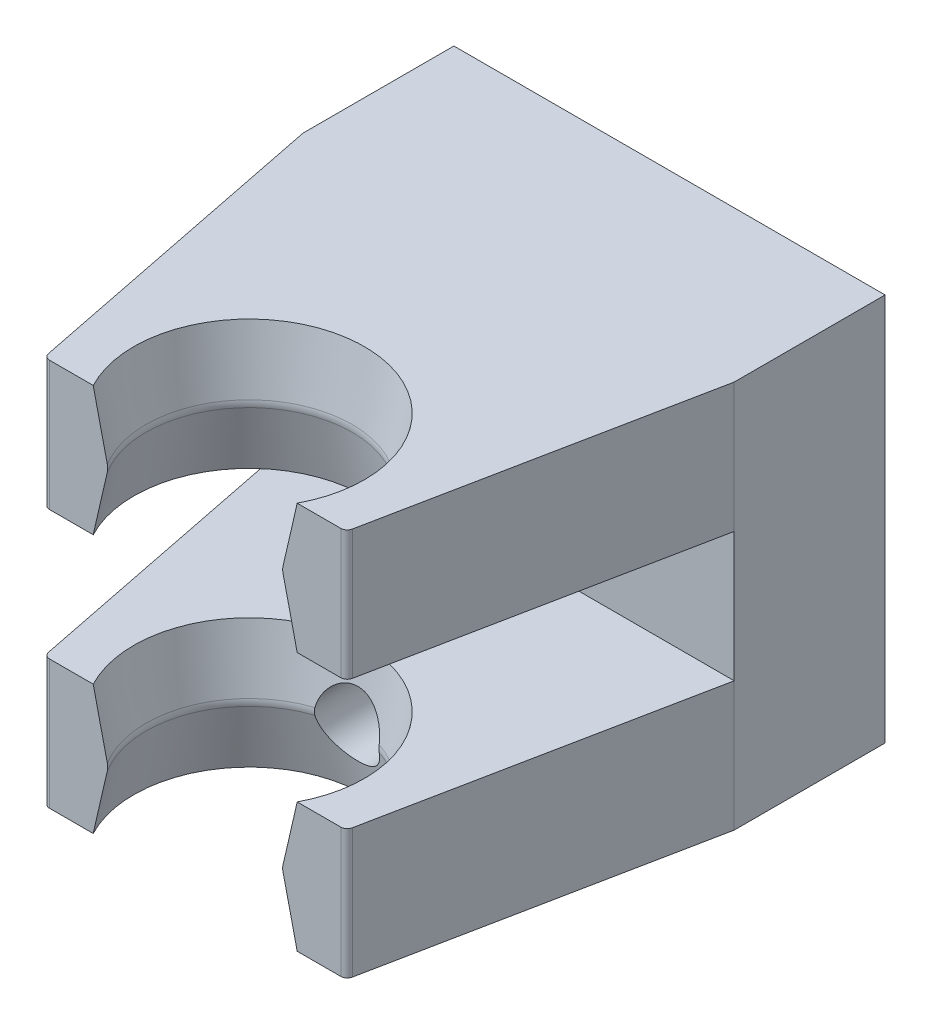
from build123d import *

# Parameters (mm, degrees)
SKETCH1_W               = 20
SKETCH1_H               = 18
BOSS_EXTRUDE1_DEPTH     = 7
SKETCH2_W               = 20
SKETCH2_H               = 6
BOSS_EXTRUDE2_DEPTH     = 15
SKETCH3_R               = 5.35
CUT_EXTRUDE1_DEPTH      = 18
SKETCH5_W               = 14
SKETCH5_H               = 6
CUT_EXTRUDE2_DEPTH      = 3.85
FILLET1_R               = 0.3
SKETCH6_W               = 20
SKETCH6_H               = 9
CUT_EXTRUDE3_DEPTH      = 16.0000001
CUT_EXTRUDE3_DEPTH_BACK = 8
SKETCH7_R               = 1.5
CUT_EXTRUDE4_DEPTH      = 1
CUT_EXTRUDE4_DEPTH_BACK = 23.0000001


with BuildPart() as part:
    # Sketch1 → Boss-Extrude1 (new body)
    with BuildSketch(Plane.XY):
        Rectangle(SKETCH1_W, SKETCH1_H)
    extrude(amount=BOSS_EXTRUDE1_DEPTH)

    # Sketch2 → Boss-Extrude2 (add)
    with BuildSketch(Plane.XY.offset(7)):
        with Locations((0, -6)):
            Rectangle(SKETCH2_W, SKETCH2_H)
        with Locations((0, 6)):
            Rectangle(SKETCH2_W, SKETCH2_H)
    extrude(amount=BOSS_EXTRUDE2_DEPTH)

    # Sketch3 → Cut-Extrude1 (cut)
    with BuildSketch(Plane.XZ.offset(9)):
        with Locations((0, 19.5)):
            Circle(SKETCH3_R)
        Polygon((-7, 22), (-10, 7), (-10, 22), align=None)
        Polygon((7, 22), (10, 22), (10, 7), align=None)
    extrude(amount=-CUT_EXTRUDE1_DEPTH, mode=Mode.SUBTRACT)

    # Sketch4 → Revolve4 (revolve)
    with BuildSketch(Plane.XY.offset(19.5)):
        with BuildLine():
            Line((-5.35, -3), (-5.35, -9))
            Line((-5.35, -9), (-4.781378582, -6.156892908))
            ThreePointArc((-4.781378582, -6.156892908), (-4.765843122, -6), (-4.781378582, -5.843107092))
            Line((-4.781378582, -5.843107092), (-5.35, -3))
        make_face()
    revolve(axis=Axis((0, -3, 19.5), (0, -1, 0)))

    # Sketch5 → Cut-Extrude2 (cut, through all)
    with BuildSketch(Plane.XY.offset(22)):
        with Locations((0, -6)):
            Rectangle(SKETCH5_W, SKETCH5_H)
    extrude(amount=CUT_EXTRUDE2_DEPTH, mode=Mode.SUBTRACT)

    # Fillet1
    fillet1_edges = [part.edges().sort_by_distance(p)[0] for p in [
        (7, -6, 22),
        (-7, -6, 22),
        (-7, 6, 22),
        (7, 6, 22),
        (-4.729957717, 6, 22),
        (4.729957717, 6, 22),
    ]]
    fillet(fillet1_edges, radius=FILLET1_R)

    # Sketch6 → Cut-Extrude3 (cut, two sides)
    with BuildSketch(Plane.XY.offset(7)) as cut_extrude3_sk:
        with Locations((0, 4.5)):
            Rectangle(SKETCH6_W, SKETCH6_H)
    extrude(amount=CUT_EXTRUDE3_DEPTH, mode=Mode.SUBTRACT)
    extrude(cut_extrude3_sk.sketch, amount=-CUT_EXTRUDE3_DEPTH_BACK, mode=Mode.SUBTRACT)

    # Mirror2: part across plane


with BuildPart() as part_1:
    add(part.part)
    add(part.part.mirror(Plane(origin=(-10, 0, 0), x_dir=(0, 0, 1), z_dir=(0, -1, 0))))

    # Sketch7 → Cut-Extrude4 (cut, two sides)
    with BuildSketch(Plane(origin=(0, 0, 0), x_dir=(-1, 0, 0), z_dir=(0, 0, -1))) as cut_extrude4_sk:
        with Locations((0, -6)):
            Circle(SKETCH7_R)
    extrude(amount=CUT_EXTRUDE4_DEPTH, mode=Mode.SUBTRACT)
    extrude(cut_extrude4_sk.sketch, amount=-CUT_EXTRUDE4_DEPTH_BACK, mode=Mode.SUBTRACT)


solid = part_1.part
